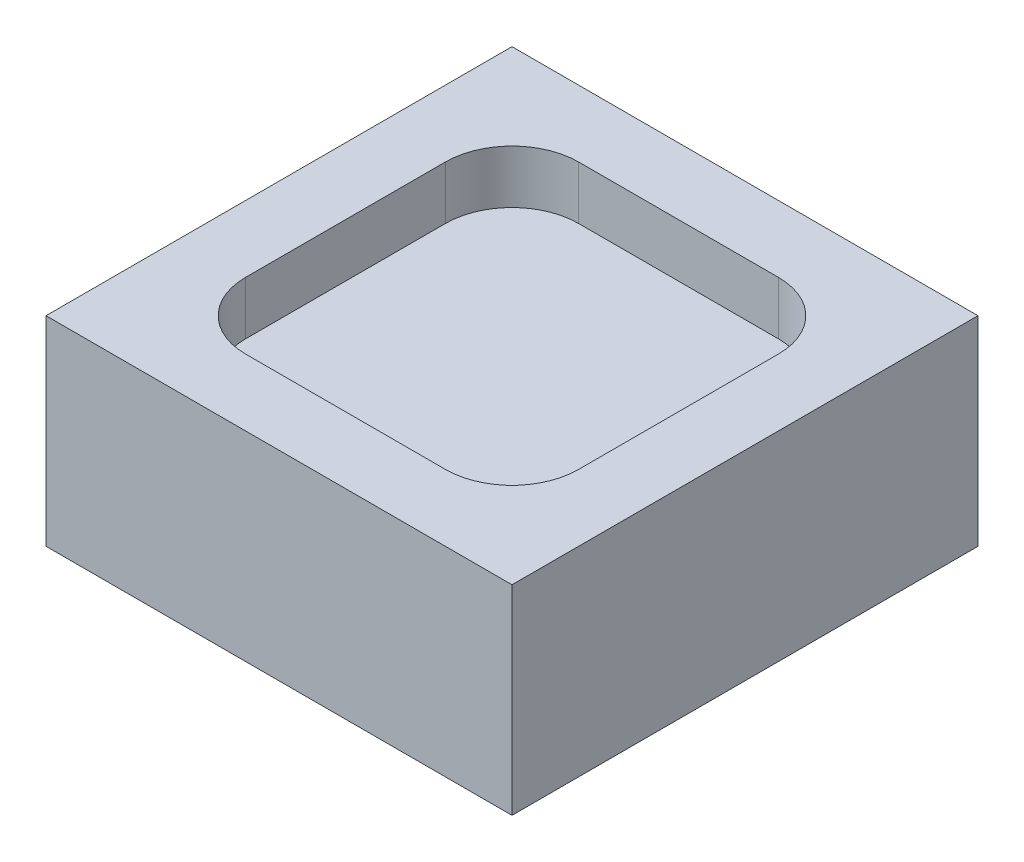
from build123d import *

# Parameters (mm, degrees)
SKETCH1_W           = 7
SKETCH1_H           = 7
BOSS_EXTRUDE1_DEPTH = 3
CUT_EXTRUDE1_DEPTH  = 0.8


with BuildPart() as part:
    # Sketch1 → Boss-Extrude1 (new body)
    with BuildSketch(Plane(origin=(0, 0, 0), x_dir=(1, 0, 0), z_dir=(0, 1, 0))):
        Rectangle(SKETCH1_W, SKETCH1_H)
    extrude(amount=BOSS_EXTRUDE1_DEPTH)

    # Sketch2 → Cut-Extrude1 (cut)
    with BuildSketch(Plane(origin=(0, 3, 0), x_dir=(1, 0, 0), z_dir=(0, 1, 0))):
        with BuildLine():
            Line((-1.5, 2.5), (1.5, 2.5))
            ThreePointArc((1.5, 2.5), (2.207106781, 2.207106781), (2.5, 1.5))
            Line((2.5, 1.5), (2.5, -1.5))
            ThreePointArc((2.5, -1.5), (2.207106781, -2.207106781), (1.5, -2.5))
            Line((1.5, -2.5), (-1.5, -2.5))
            ThreePointArc((-1.5, -2.5), (-2.207106781, -2.207106781), (-2.5, -1.5))
            Line((-2.5, -1.5), (-2.5, 1.5))
            ThreePointArc((-2.5, 1.5), (-2.207106781, 2.207106781), (-1.5, 2.5))
        make_face()
    extrude(amount=-CUT_EXTRUDE1_DEPTH, mode=Mode.SUBTRACT)


solid = part.part
